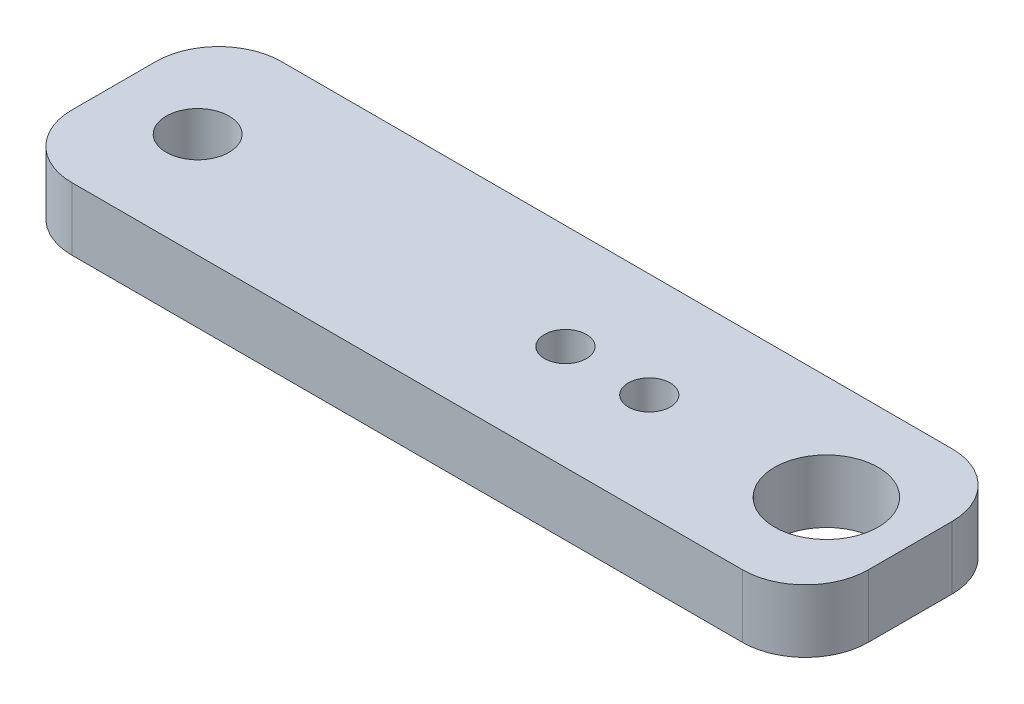
from build123d import *

# Parameters (mm, degrees)
SKETCH1_W                = 38
SKETCH1_H                = 10
BOSS_EXTRUDE1_DEPTH      = 3
SKETCH2_R                = 2.472864358
SKETCH2_R_2              = 1
CUT_EXTRUDE1_DEPTH       = 3
FILLET1_R                = 3
F_3_0_3_DIAMETER_HOLE1_D = 3


with BuildPart() as part:
    # Sketch1 → Boss-Extrude1 (new body)
    with BuildSketch(Plane(origin=(0, 0, 0), x_dir=(1, 0, 0), z_dir=(0, 1, 0))):
        Rectangle(SKETCH1_W, SKETCH1_H)
    extrude(amount=BOSS_EXTRUDE1_DEPTH)

    # Sketch2 → Cut-Extrude1 (cut)
    with BuildSketch(Plane(origin=(0, 3, 0), x_dir=(1, 0, 0), z_dir=(0, 1, 0))):
        with Locations((15, 0)):
            Circle(SKETCH2_R)
        with Locations((6.55, 0)):
            Circle(SKETCH2_R_2)
        with Locations((2.55, 0)):
            Circle(SKETCH2_R_2)
    extrude(amount=-CUT_EXTRUDE1_DEPTH, mode=Mode.SUBTRACT)

    # Fillet1
    fillet1_edges = [part.edges().sort_by_distance(p)[0] for p in [
        (19, 1.5, 5),
        (-19, 1.5, 5),
        (-19, 1.5, -5),
        (19, 1.5, -5),
    ]]
    fillet(fillet1_edges, radius=FILLET1_R)

    # Ø3.0 (3) Diameter Hole1 (through all)
    with Locations(Plane(origin=(0, 3, 0), x_dir=(1, 0, 0), z_dir=(0, 1, 0))):
        with Locations((-15, 0)):
            Hole(F_3_0_3_DIAMETER_HOLE1_D / 2)


solid = part.part
